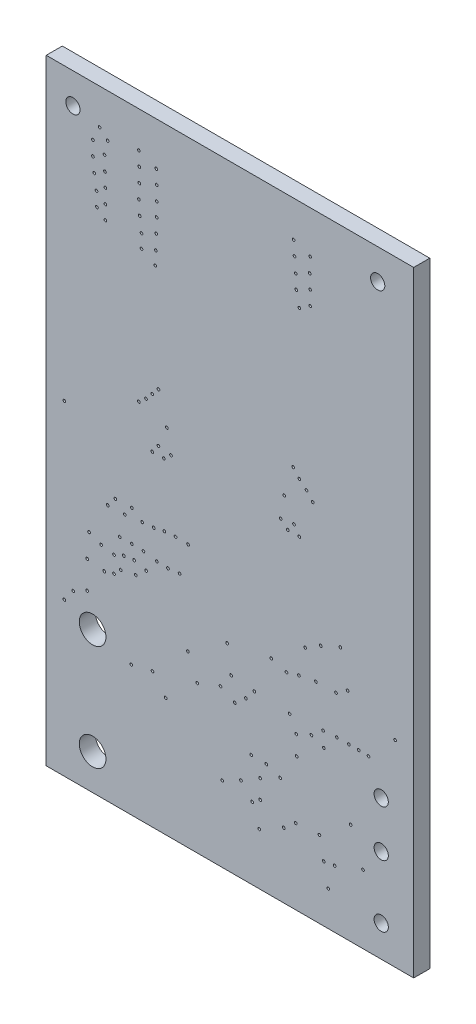
from build123d import *

# Parameters (mm, degrees)
SKETCH1_W           = 20.931
SKETCH1_H           = 35.052
BOARD_OUTLINE_DEPTH = 0.9144
SKETCH2_R           = 0.0762
NPTH_DEPTH          = 1.9144
SKETCH3_R           = 0.405
SKETCH3_R_2         = 0.76
PTH_DEPTH           = 1.9144


with BuildPart() as part:
    # Sketch1 → Board_Outline (new body)
    with BuildSketch(Plane.XY):
        with Locations((10.4655, 17.526)):
            Rectangle(SKETCH1_W, SKETCH1_H)
    extrude(amount=BOARD_OUTLINE_DEPTH)

    # Sketch2 → NPTH (cut, through all)
    with BuildSketch(Plane.XY):
        with Locations((14.2414, 8.6868)):
            Circle(SKETCH2_R)
        with Locations((6.0499, 7.6962)):
            Circle(SKETCH2_R)
        with Locations((9.9234, 8.89)):
            Circle(SKETCH2_R)
        with Locations((4.8434, 7.4168)):
            Circle(SKETCH2_R)
        with Locations((10.533, 9.7282)):
            Circle(SKETCH2_R)
        with Locations((19.87, 11.21)):
            Circle(SKETCH2_R)
        with Locations((6.8678, 20.1168)):
            Circle(SKETCH2_R)
        with Locations((13.5556, 20.1168)):
            Circle(SKETCH2_R)
        with Locations((11.0918, 4.826)):
            Circle(SKETCH2_R)
        with Locations((1.5414, 9.398)):
            Circle(SKETCH2_R)
        with Locations((11.3712, 9.017)):
            Circle(SKETCH2_R)
        with Locations((13.8604, 9.4996)):
            Circle(SKETCH2_R)
        with Locations((14.21, 4.28)):
            Circle(SKETCH2_R)
        with Locations((18.04, 3.9)):
            Circle(SKETCH2_R)
        with Locations((17.7974, 9.6774)):
            Circle(SKETCH2_R)
        with Locations((8.6026, 8.382)):
            Circle(SKETCH2_R)
        with Locations((17.2386, 9.6774)):
            Circle(SKETCH2_R)
        with Locations((10.025, 4.2926)):
            Circle(SKETCH2_R)
        with Locations((12.184, 4.4196)):
            Circle(SKETCH2_R)
        with Locations((12.184, 5.4864)):
            Circle(SKETCH2_R)
        with Locations((16.5528, 9.6774)):
            Circle(SKETCH2_R)
        with Locations((15.7654, 9.6266)):
            Circle(SKETCH2_R)
        with Locations((13.327, 6.0706)):
            Circle(SKETCH2_R)
        with Locations((11.7268, 4.0894)):
            Circle(SKETCH2_R)
        with Locations((2.3311, 11.3792)):
            Circle(SKETCH2_R)
        with Locations((3.04, 33.02)):
            Circle(SKETCH2_R)
        with Locations((3.302, 11.2522)):
            Circle(SKETCH2_R)
        with Locations((3.4972, 32.5882)):
            Circle(SKETCH2_R)
        with Locations((3.8608, 11.4046)):
            Circle(SKETCH2_R)
        with Locations((2.659, 32.2072)):
            Circle(SKETCH2_R)
        with Locations((4.2418, 11.7856)):
            Circle(SKETCH2_R)
        with Locations((3.3194, 31.8008)):
            Circle(SKETCH2_R)
        with Locations((5.1054, 11.9634)):
            Circle(SKETCH2_R)
        with Locations((2.659, 31.3944)):
            Circle(SKETCH2_R)
        with Locations((2.4384, 12.7508)):
            Circle(SKETCH2_R)
        with Locations((3.3448, 30.988)):
            Circle(SKETCH2_R)
        with Locations((3.1242, 12.4714)):
            Circle(SKETCH2_R)
        with Locations((2.7352, 30.607)):
            Circle(SKETCH2_R)
        with Locations((3.8608, 12.3444)):
            Circle(SKETCH2_R)
        with Locations((3.3702, 30.2006)):
            Circle(SKETCH2_R)
        with Locations((4.4196, 12.573)):
            Circle(SKETCH2_R)
        with Locations((2.8622, 29.7942)):
            Circle(SKETCH2_R)
        with Locations((5.0038, 12.6492)):
            Circle(SKETCH2_R)
        with Locations((3.3702, 29.3878)):
            Circle(SKETCH2_R)
        with Locations((5.6896, 12.4714)):
            Circle(SKETCH2_R)
        with Locations((2.8876, 29.0068)):
            Circle(SKETCH2_R)
        with Locations((4.191, 13.3858)):
            Circle(SKETCH2_R)
        with Locations((3.3702, 28.6004)):
            Circle(SKETCH2_R)
        with Locations((4.8768, 13.3858)):
            Circle(SKETCH2_R)
        with Locations((5.2752, 32.9946)):
            Circle(SKETCH2_R)
        with Locations((5.5372, 13.3604)):
            Circle(SKETCH2_R)
        with Locations((6.2658, 32.5882)):
            Circle(SKETCH2_R)
        with Locations((6.2992, 13.2334)):
            Circle(SKETCH2_R)
        with Locations((5.3006, 32.2072)):
            Circle(SKETCH2_R)
        with Locations((6.9342, 13.208)):
            Circle(SKETCH2_R)
        with Locations((6.2912, 31.8008)):
            Circle(SKETCH2_R)
        with Locations((7.5946, 13.2842)):
            Circle(SKETCH2_R)
        with Locations((5.3006, 31.3944)):
            Circle(SKETCH2_R)
        with Locations((3.5052, 14.605)):
            Circle(SKETCH2_R)
        with Locations((6.2912, 30.988)):
            Circle(SKETCH2_R)
        with Locations((3.937, 15.1384)):
            Circle(SKETCH2_R)
        with Locations((5.2752, 30.5816)):
            Circle(SKETCH2_R)
        with Locations((4.4704, 14.6304)):
            Circle(SKETCH2_R)
        with Locations((6.2912, 30.2006)):
            Circle(SKETCH2_R)
        with Locations((4.8768, 15.1638)):
            Circle(SKETCH2_R)
        with Locations((5.326, 29.7942)):
            Circle(SKETCH2_R)
        with Locations((5.461, 14.7574)):
            Circle(SKETCH2_R)
        with Locations((6.2658, 29.3878)):
            Circle(SKETCH2_R)
        with Locations((6.1214, 14.8082)):
            Circle(SKETCH2_R)
        with Locations((5.4276, 28.9814)):
            Circle(SKETCH2_R)
        with Locations((6.731, 14.9352)):
            Circle(SKETCH2_R)
        with Locations((6.2404, 28.5496)):
            Circle(SKETCH2_R)
        with Locations((7.366, 14.986)):
            Circle(SKETCH2_R)
        with Locations((5.4276, 28.2194)):
            Circle(SKETCH2_R)
        with Locations((8.0772, 14.9606)):
            Circle(SKETCH2_R)
        with Locations((6.215, 27.7876)):
            Circle(SKETCH2_R)
        with Locations((6.0372, 18.5166)):
            Circle(SKETCH2_R)
        with Locations((5.2752, 20.5994)):
            Circle(SKETCH2_R)
        with Locations((6.3928, 18.9738)):
            Circle(SKETCH2_R)
        with Locations((5.6816, 20.955)):
            Circle(SKETCH2_R)
        with Locations((6.6976, 18.5166)):
            Circle(SKETCH2_R)
        with Locations((6.0372, 21.3614)):
            Circle(SKETCH2_R)
        with Locations((7.104, 18.8722)):
            Circle(SKETCH2_R)
        with Locations((6.3928, 21.7678)):
            Circle(SKETCH2_R)
        with Locations((14.089, 32.9946)):
            Circle(SKETCH2_R)
        with Locations((12.819, 11.7094)):
            Circle(SKETCH2_R)
        with Locations((15.0288, 32.639)):
            Circle(SKETCH2_R)
        with Locations((13.6826, 11.4554)):
            Circle(SKETCH2_R)
        with Locations((14.1398, 32.2072)):
            Circle(SKETCH2_R)
        with Locations((14.3938, 11.6586)):
            Circle(SKETCH2_R)
        with Locations((15.0034, 31.8008)):
            Circle(SKETCH2_R)
        with Locations((15.359, 11.8364)):
            Circle(SKETCH2_R)
        with Locations((14.216, 31.3944)):
            Circle(SKETCH2_R)
        with Locations((16.502, 11.8618)):
            Circle(SKETCH2_R)
        with Locations((15.0288, 31.0134)):
            Circle(SKETCH2_R)
        with Locations((17.1624, 12.2936)):
            Circle(SKETCH2_R)
        with Locations((14.2414, 30.607)):
            Circle(SKETCH2_R)
        with Locations((14.7494, 13.208)):
            Circle(SKETCH2_R)
        with Locations((15.0288, 30.2006)):
            Circle(SKETCH2_R)
        with Locations((15.6384, 13.7414)):
            Circle(SKETCH2_R)
        with Locations((14.4192, 29.7942)):
            Circle(SKETCH2_R)
        with Locations((16.756, 14.224)):
            Circle(SKETCH2_R)
        with Locations((14.4192, 18.5166)):
            Circle(SKETCH2_R)
        with Locations((15.1812, 20.5994)):
            Circle(SKETCH2_R)
        with Locations((14.1144, 18.9738)):
            Circle(SKETCH2_R)
        with Locations((14.8256, 21.0058)):
            Circle(SKETCH2_R)
        with Locations((13.7588, 18.5166)):
            Circle(SKETCH2_R)
        with Locations((14.4192, 21.3614)):
            Circle(SKETCH2_R)
        with Locations((13.3524, 18.8722)):
            Circle(SKETCH2_R)
        with Locations((14.0636, 21.7678)):
            Circle(SKETCH2_R)
        with Locations((16.0702, 1.9812)):
            Circle(SKETCH2_R)
        with Locations((12.5396, 6.35)):
            Circle(SKETCH2_R)
        with Locations((15.8094, 3.195)):
            Circle(SKETCH2_R)
        with Locations((10.7362, 8.4836)):
            Circle(SKETCH2_R)
        with Locations((17.3402, 5.7658)):
            Circle(SKETCH2_R)
        with Locations((15.5622, 4.3688)):
            Circle(SKETCH2_R)
        with Locations((16.4296, 3.2888)):
            Circle(SKETCH2_R)
        with Locations((11.676, 6.3754)):
            Circle(SKETCH2_R)
        with Locations((1.0334, 18.5166)):
            Circle(SKETCH2_R)
        with Locations((1.0334, 8.7122)):
            Circle(SKETCH2_R)
        with Locations((10.3044, 11.2014)):
            Circle(SKETCH2_R)
        with Locations((15.8162, 8.7884)):
            Circle(SKETCH2_R)
        with Locations((13.5302, 3.7084)):
            Circle(SKETCH2_R)
        with Locations((15.105, 9.0678)):
            Circle(SKETCH2_R)
        with Locations((12.1332, 2.9464)):
            Circle(SKETCH2_R)
        with Locations((14.2636, 7.6016)):
            Circle(SKETCH2_R)
        with Locations((2.3288, 9.8044)):
            Circle(SKETCH2_R)
        with Locations((8.0692, 9.6774)):
            Circle(SKETCH2_R)
        with Locations((11.8538, 9.6012)):
            Circle(SKETCH2_R)
        with Locations((18.3562, 9.652)):
            Circle(SKETCH2_R)
        with Locations((6.7992, 6.7564)):
            Circle(SKETCH2_R)
    extrude(amount=NPTH_DEPTH, mode=Mode.SUBTRACT)

    # Sketch3 → PTH (cut, through all)
    with BuildSketch(Plane.XY):
        with Locations((19.08, 5.31)):
            Circle(SKETCH3_R)
        with Locations((18.88, 33.32)):
            Circle(SKETCH3_R)
        with Locations((2.64, 8.05)):
            Circle(SKETCH3_R_2)
        with Locations((2.64, 2.03)):
            Circle(SKETCH3_R_2)
        with Locations((19.08, 7.96)):
            Circle(SKETCH3_R)
        with Locations((1.52, 33.32)):
            Circle(SKETCH3_R)
        with Locations((19.08, 1.78)):
            Circle(SKETCH3_R)
    extrude(amount=PTH_DEPTH, mode=Mode.SUBTRACT)


solid = part.part
